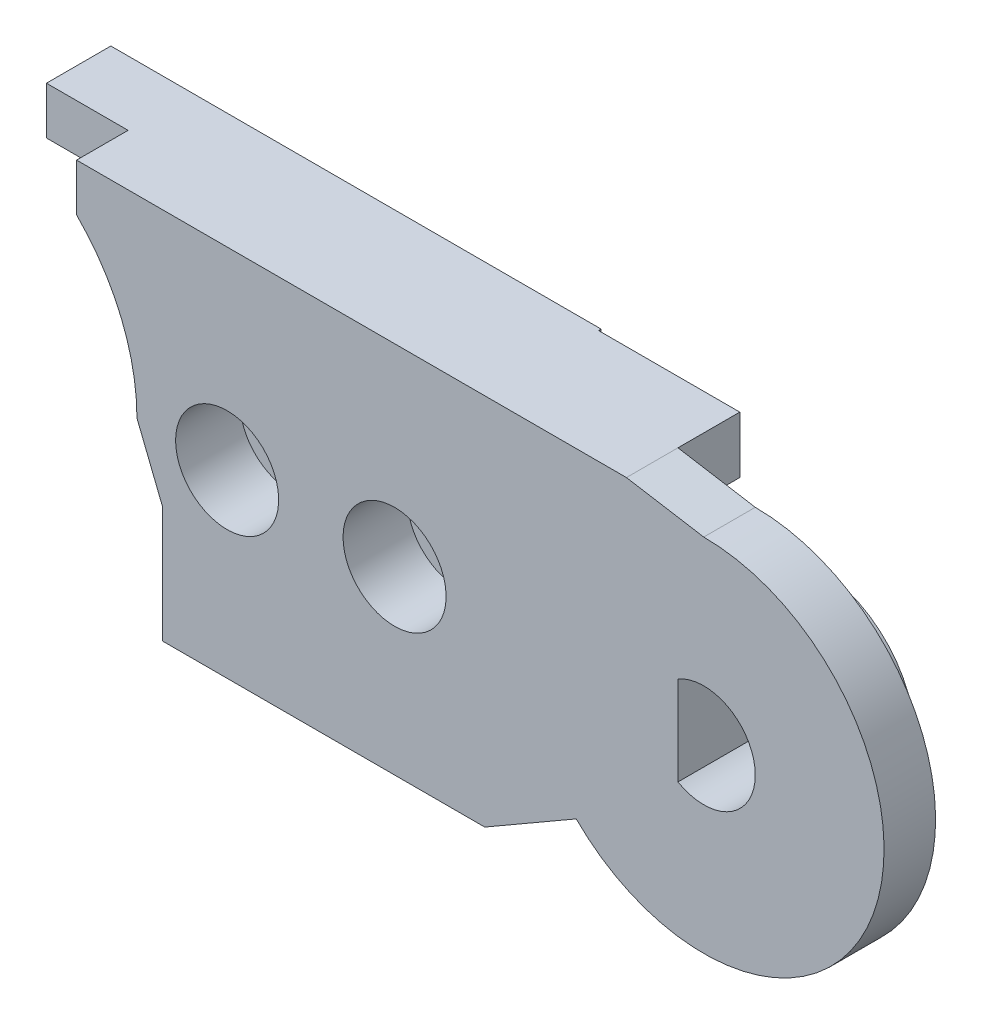
from build123d import *

# Parameters (mm, degrees)
BOSS_EXTRUDE1_DEPTH  = 2
BOSS_EXTRUDE6_DEPTH  = 2.5
CUT_EXTRUDE6_DEPTH   = 2.5
BOSS_EXTRUDE14_DEPTH = 2.3
SKETCH32_R           = 2.1
CUT_EXTRUDE7_DEPTH   = 2.3
SKETCH33_W           = 12.5
SKETCH33_H           = 1.343145751
BOSS_EXTRUDE15_DEPTH = 1.2
SKETCH35_W           = 5.479645997
SKETCH35_H           = 5.327993755
CUT_EXTRUDE8_DEPTH   = 2.4
SKETCH36_W           = 3.7
SKETCH36_H           = 1.827993755
CUT_EXTRUDE9_DEPTH   = 2.4
SKETCH37_R           = 3.9
BOSS_EXTRUDE16_DEPTH = 2.3
CUT_EXTRUDE10_DEPTH  = 5.3
SKETCH43_R           = 2.5
BOSS_EXTRUDE17_DEPTH = 1.2
SKETCH44_R           = 0.95
CUT_EXTRUDE11_DEPTH  = 9
SKETCH45_R           = 2
CUT_EXTRUDE12_DEPTH  = 2.5
SKETCH52_R           = 0.75
CUT_EXTRUDE13_DEPTH  = 10


with BuildPart() as part:
    # Sketch3 → Boss-Extrude1 (new body)
    with BuildSketch(Plane.XY):
        with BuildLine():
            Line((8, 0), (9, -2.5))
            Line((9, -2.5), (9, -7))
            Line((9, -7), (21.5, -7))
            Line((21.5, -7), (25.050252532, -4.949747468))
            ThreePointArc((25.050252532, -4.949747468), (36.467156728, -2.678784027), (30, 7))
            Line((30, 7), (27, 7.5))
            Line((27, 7.5), (5.656854249, 7.5))
            Line((5.656854249, 7.5), (5.656854249, 5.656854249))
            ThreePointArc((5.656854249, 5.656854249), (7.39103626, 3.061467459), (8, 0))
        make_face()
    extrude(amount=BOSS_EXTRUDE1_DEPTH)

    # Sketch22 → Boss-Extrude6 (add)
    with BuildSketch(Plane.XY.offset(2)):
        with BuildLine():
            Line((5.656854249, 5.656854249), (2.486790148, 5.656854249))
            Line((2.486790148, 5.656854249), (2.486790148, 7.5))
            Line((2.486790148, 7.5), (5.656854249, 7.5))
            Line((5.656854249, 7.5), (21.5, 7.5))
            Line((21.5, 7.5), (27, 7.5))
            Line((27, 7.5), (27, 2.172006245))
            Line((27, 2.172006245), (23.275126266, 2.172006245))
            Line((23.275126266, 2.172006245), (23.275126266, -5.974873734))
            Line((23.275126266, -5.974873734), (21.5, -7))
            Line((21.5, -7), (9, -7))
            Line((9, -7), (9, -2.5))
            Line((9, -2.5), (8, 0))
            ThreePointArc((8, 0), (7.39103626, 3.061467459), (5.656854249, 5.656854249))
        make_face()
    extrude(amount=BOSS_EXTRUDE6_DEPTH)

    # Sketch26 → Cut-Extrude6 (cut)
    with BuildSketch(Plane.XY.offset(2)):
        Polygon((18.098080448, 5.3), (2.530052458, 5.3), (2.530052458, 4), (18.098080448, 4), (27, 4), (27, 5.3), align=None)
    extrude(amount=CUT_EXTRUDE6_DEPTH, mode=Mode.SUBTRACT)


with BuildPart() as body_2:
    # Sketch31 → Boss-Extrude14 (new body)
    with BuildSketch(Plane.XY.offset(4.5)):
        with BuildLine():
            Line((2.432688066, 5.656854249), (0, 5.656854249))
            ThreePointArc((0, 5.656854249), (-5.656854249, 0), (0, -5.656854249))
            Line((0, -5.656854249), (9, -5.656854249))
            Line((9, -5.656854249), (9, -7))
            Line((9, -7), (21.5, -7))
            Line((21.5, -7), (23.275126266, -5.974873734))
            Line((23.275126266, -5.974873734), (23.275126266, 2.172006245))
            Line((23.275126266, 2.172006245), (27, 2.172006245))
            Line((27, 2.172006245), (27, 7.5))
            Line((27, 7.5), (2.486790148, 7.5))
            Line((2.486790148, 7.5), (2.432688066, 5.656854249))
        make_face()
    extrude(amount=BOSS_EXTRUDE14_DEPTH)

    # Sketch32 → Cut-Extrude7 (cut)
    with BuildSketch(Plane.XY.offset(6.8)):
        Circle(SKETCH32_R)
    extrude(amount=-CUT_EXTRUDE7_DEPTH, mode=Mode.SUBTRACT)

    # Sketch33 → Boss-Extrude15 (add)
    with BuildSketch(Plane.XY.offset(6.8)):
        with Locations((15.25, -6.328427125)):
            Rectangle(SKETCH33_W, SKETCH33_H)
        Polygon((2.486790148, 7.5), (21.5, 7.5), (21.5, 5.656854249), (2.432688066, 5.656854249), align=None)
    extrude(amount=BOSS_EXTRUDE15_DEPTH)


with BuildPart() as cut_extrude8_tool:
    # Sketch35 → Cut-Extrude8 (new body)
    with BuildSketch(Plane.XY.offset(6.8)):
        with Locations((24.260177002, 4.836003123)):
            Rectangle(SKETCH35_W, SKETCH35_H)
    extrude(amount=-CUT_EXTRUDE8_DEPTH)


with BuildPart() as part_1:
    add(part.part)

    # Cut-Extrude8: cut by cut_extrude8_tool
    add(cut_extrude8_tool.part, mode=Mode.SUBTRACT)

    # Sketch36 → Cut-Extrude9 (cut)
    with BuildSketch(Plane.XY.offset(4.4)):
        with Locations((25.15, 3.086003123)):
            Rectangle(SKETCH36_W, SKETCH36_H)
    extrude(amount=-CUT_EXTRUDE9_DEPTH, mode=Mode.SUBTRACT)

    # Sketch37 → Boss-Extrude16 (add)
    with BuildSketch(Plane.XY.offset(2)):
        with Locations((30, 0)):
            Circle(SKETCH37_R)
    extrude(amount=BOSS_EXTRUDE16_DEPTH)

    # Sketch39 → Cut-Extrude10 (cut, through all)
    with BuildSketch(Plane.XY.offset(4.3)):
        with BuildLine():
            Line((29, 1.732050808), (29, -1.732050808))
            ThreePointArc((29, -1.732050808), (32, 0), (29, 1.732050808))
        make_face()
    extrude(amount=-CUT_EXTRUDE10_DEPTH, mode=Mode.SUBTRACT)


with BuildPart() as body_2_1:
    add(body_2.part)

    # Cut-Extrude8: cut by cut_extrude8_tool
    add(cut_extrude8_tool.part, mode=Mode.SUBTRACT)

    # Sketch43 → Boss-Extrude17 (add)
    with BuildSketch(Plane.XY.offset(6.8)):
        with Locations((11.5, 0)):
            Circle(SKETCH43_R)
        with Locations((18, 0)):
            Circle(SKETCH43_R)
    extrude(amount=BOSS_EXTRUDE17_DEPTH)


with BuildPart() as cut_extrude11_tool:
    # Sketch44 → Cut-Extrude11 (new body, through all)
    with BuildSketch(Plane.XY.offset(8)):
        with Locations((11.5, 0)):
            Circle(SKETCH44_R)
        with Locations((18, 0)):
            Circle(SKETCH44_R)
    extrude(amount=-CUT_EXTRUDE11_DEPTH)


with BuildPart() as part_2:
    add(part_1.part)

    # Cut-Extrude11: cut by cut_extrude11_tool
    add(cut_extrude11_tool.part, mode=Mode.SUBTRACT)

    # Sketch45 → Cut-Extrude12 (cut)
    with BuildSketch(Plane(origin=(0, 0, 0), x_dir=(-1, 0, 0), z_dir=(0, 0, -1))):
        with Locations((-11.5, 0)):
            Circle(SKETCH45_R)
        with Locations((-18, 0)):
            Circle(SKETCH45_R)
    extrude(amount=-CUT_EXTRUDE12_DEPTH, mode=Mode.SUBTRACT)


with BuildPart() as body_2_2:
    add(body_2_1.part)

    # Cut-Extrude11: cut by cut_extrude11_tool
    add(cut_extrude11_tool.part, mode=Mode.SUBTRACT)

    # Sketch52 → Cut-Extrude13 (cut, along a direction that is not the sketch's normal)
    with BuildSketch(Plane.XZ.offset(-5.656854249)):
        with Locations((18.235476819, 8)):
            Circle(SKETCH52_R)
    extrude(amount=-CUT_EXTRUDE13_DEPTH, dir=(0.640410196, -0.76803306, 0), mode=Mode.SUBTRACT)


with BuildPart() as body_3:
    # Mirror1: mirrored copy
    add(body_2_2.part.mirror(Plane.XY.offset(8)))


with BuildPart() as body_4:
    # Mirror1 2: mirrored copy
    add(part_2.part.mirror(Plane.XY.offset(8)))


solid = body_4.part
